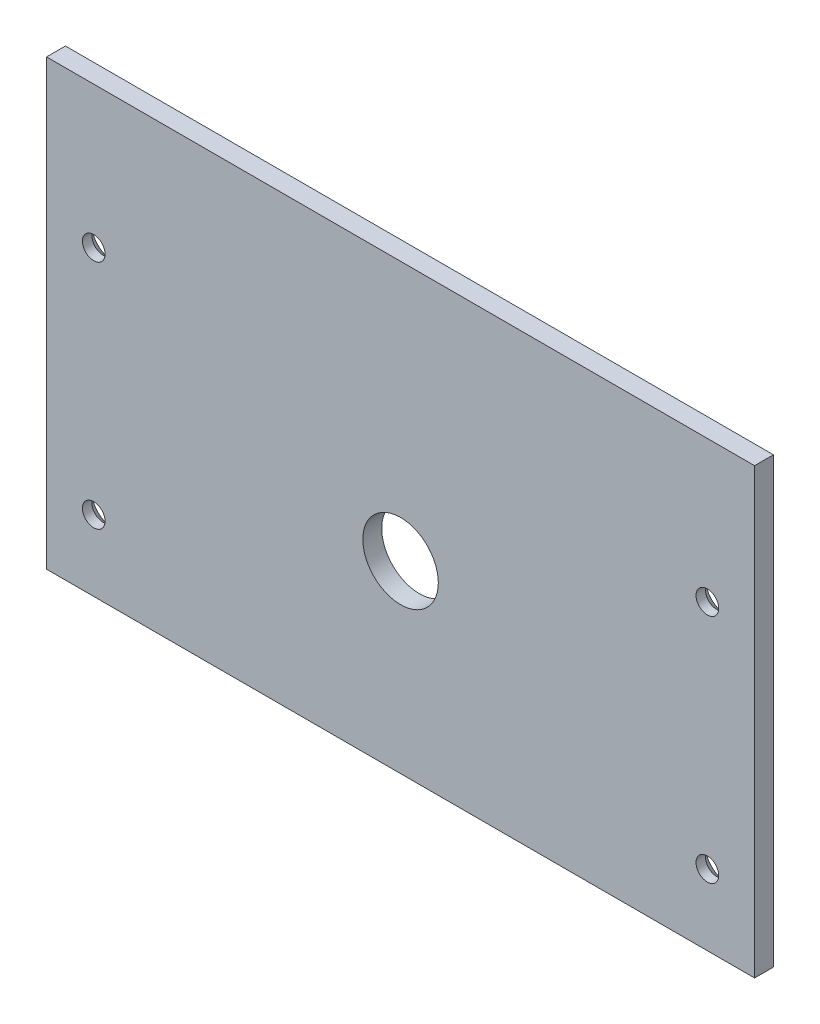
from build123d import *

# Parameters (mm, degrees)
SKETCH1_W                                    = 75
SKETCH1_H                                    = 47
BOSS_EXTRUDE1_DEPTH                          = 2
SKETCH3_R                                    = 4
CUT_EXTRUDE1_DEPTH                           = 5
CSK_FOR_M2_COUNTERSUNK_FLAT_HEAD_SCR_2_COUNT = 2
CSK_FOR_M2_COUNTERSUNK_FLAT_HEAD_SCR_2_PITCH = 24.5
CSK_FOR_M2_COUNTERSUNK_FLAT_HEAD_SCR_3_COUNT = 2
CSK_FOR_M2_COUNTERSUNK_FLAT_HEAD_SCR_3_PITCH = 65
CSK_FOR_M2_COUNTERSUNK_FLAT_HEAD_SCR_4_COUNT = 2
CSK_FOR_M2_COUNTERSUNK_FLAT_HEAD_SCR_4_PITCH = 69.464019463


with BuildPart() as part:
    # Sketch1 → Boss-Extrude1 (new body)
    with BuildSketch(Plane.XY):
        Rectangle(SKETCH1_W, SKETCH1_H)
    extrude(amount=BOSS_EXTRUDE1_DEPTH)

    # Sketch3 → Cut-Extrude1 (cut)
    with BuildSketch(Plane.XY.offset(2)):
        with Locations((0, -4)):
            Circle(SKETCH3_R)
    extrude(amount=-CUT_EXTRUDE1_DEPTH, mode=Mode.SUBTRACT)

    # Sketch5 → CSK for M2 Countersunk Flat Head Screw1 (revolve, cut)
    with BuildSketch(Plane(origin=(32.5, 8.5, 0), x_dir=(0, 1, 0), z_dir=(1, 0, 0))):
        Polygon((0, 0), (0, 2), (1.2, 2), (1.2, 1), (2.2, 0), align=None)
    csk_for_m2_countersunk_flat_head_screw1 = revolve(axis=Axis((32.5, 8.5, -6.35), (0, 0, 1)), mode=Mode.SUBTRACT)

    # CSK for M2 Countersunk Flat Head Scr 2: CSK for M2 Countersunk Flat Head Screw1 ×2
    with Locations(*[(0, -i * CSK_FOR_M2_COUNTERSUNK_FLAT_HEAD_SCR_2_PITCH, 0) for i in range(1, CSK_FOR_M2_COUNTERSUNK_FLAT_HEAD_SCR_2_COUNT)]):
        add(csk_for_m2_countersunk_flat_head_screw1, mode=Mode.SUBTRACT)

    # CSK for M2 Countersunk Flat Head Scr 3: CSK for M2 Countersunk Flat Head Screw1 ×2
    with Locations(*[(-i * CSK_FOR_M2_COUNTERSUNK_FLAT_HEAD_SCR_3_PITCH, 0, 0) for i in range(1, CSK_FOR_M2_COUNTERSUNK_FLAT_HEAD_SCR_3_COUNT)]):
        add(csk_for_m2_countersunk_flat_head_screw1, mode=Mode.SUBTRACT)

    # CSK for M2 Countersunk Flat Head Scr 4: CSK for M2 Countersunk Flat Head Screw1 ×2
    with Locations(*[Vector(-0.935736234, -0.352700581, 0) * (i * CSK_FOR_M2_COUNTERSUNK_FLAT_HEAD_SCR_4_PITCH) for i in range(1, CSK_FOR_M2_COUNTERSUNK_FLAT_HEAD_SCR_4_COUNT)]):
        add(csk_for_m2_countersunk_flat_head_screw1, mode=Mode.SUBTRACT)


solid = part.part
